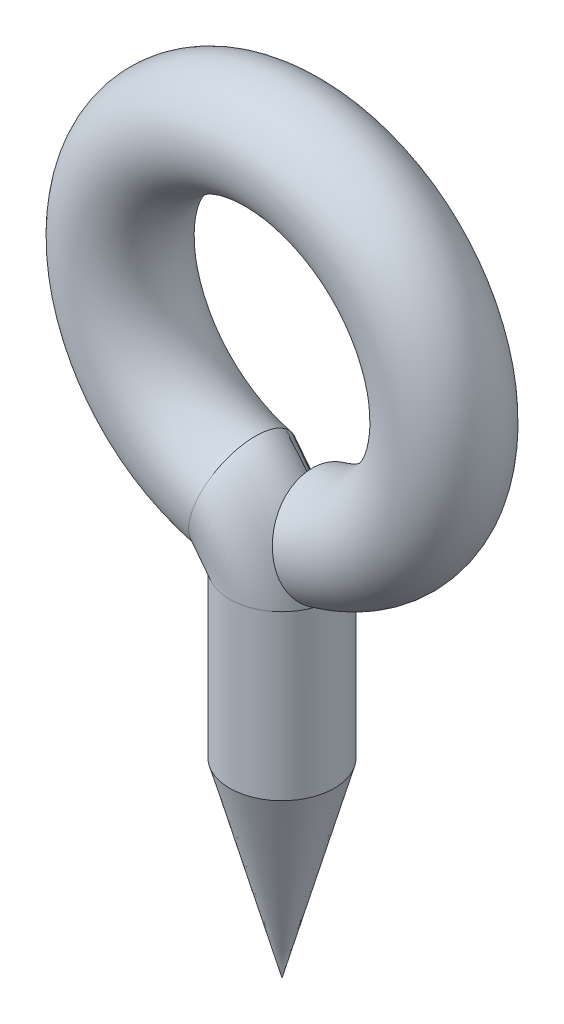
from build123d import *

# Parameters (mm, degrees)
ESQUISSE6_R = 1.1


with BuildPart() as part:
    # Balayage7: sweep along a path in Esquisse1
    with BuildLine(Plane.XY) as balayage7_path:
        Line((0, 4), (0, 7.436515154))
        ThreePointArc((0, 7.436515154), (-0.232308298, 8.112615081), (-0.831111111, 8.503144783))
        ThreePointArc((-0.831111111, 8.503144783), (-0.054917754, 15.199556448), (0.93716701, 8.531710234))
    # Esquisse6 → Balayage7 (sweep)
    with BuildSketch(Plane(origin=(0, 4, 0), x_dir=(-1, 0, 0), z_dir=(0, 1, 0))):
        Circle(ESQUISSE6_R)
    sweep(path=balayage7_path.line)

    # Esquisse7 → Révolution2 (revolve)
    with BuildSketch(Plane.XY):
        Polygon((0, 4), (-1.1, 4), (0, 0), align=None)
    revolve(axis=Axis((0, 4, 0), (0, -1, 0)))


solid = part.part
